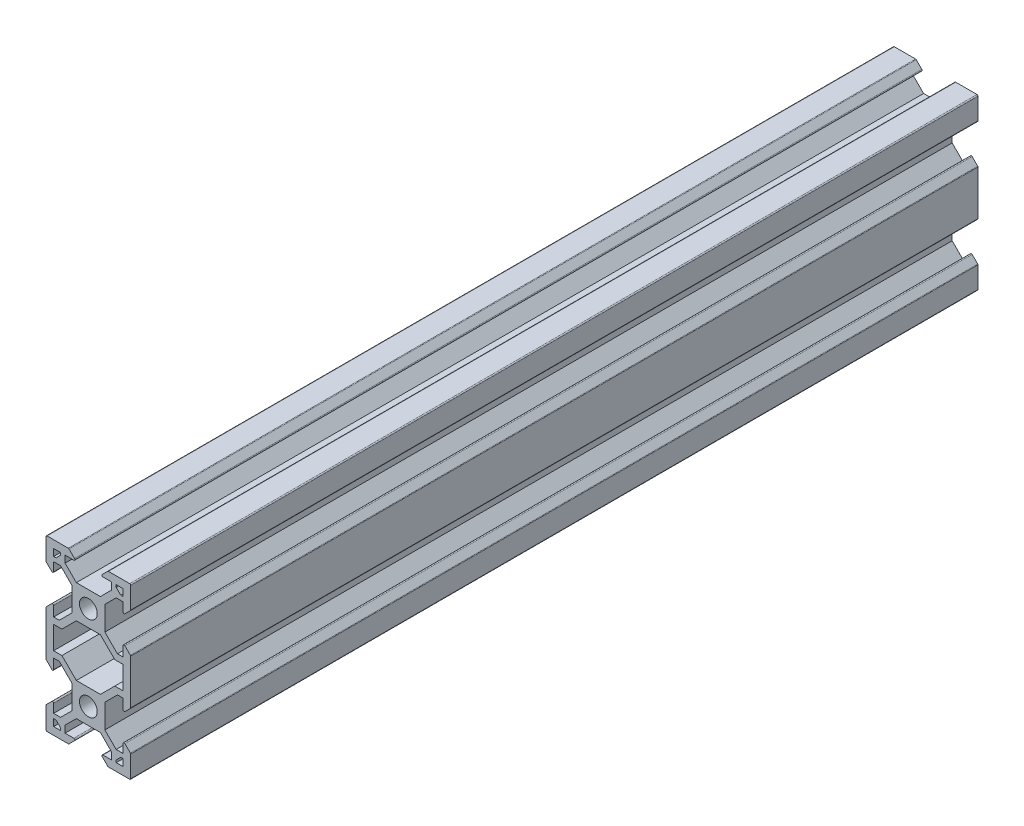
from build123d import *

# Parameters (mm, degrees)
SKETCH1_R            = 2.1
BOSS_EXTRUDE2_DEPTH  = 200
CUT_EXTRUDE1_DEPTH   = 201
FILLET1_R            = 0.25
FILLET1_OF_MIRROR1_R = 0.25


with BuildPart() as part:
    # Sketch1 → Boss-Extrude2 (new body)
    with BuildSketch(Plane.XY):
        Polygon((8.199993721, -10), (9.999993721, -10), (9.999993721, -4.63999575), (8.199993721, -2.84), (8.199993721, -5.800653822), (6.861313026, -5.800653822), (3.900652213, -2.84), (3.900652213, 2.84), (6.559993721, 5.499347787), (8.199993721, 5.499347787), (8.199993721, 2.84), (9.999993721, 4.64000425), (9.999993721, 10), (4.63999575, 10), (2.84, 8.2), (5.499325592, 8.2), (5.499325592, 6.56), (2.84, 3.900668129), (-2.84, 3.900668129), (-5.49933815, 6.56), (-5.49933815, 8.2), (-2.84, 8.2), (-4.64000425, 10), (-10.000006279, 10), (-10.000006279, 4.63999575), (-8.200006279, 2.84), (-8.200006279, 5.499347787), (-6.560006279, 5.499347787), (-3.900652213, 2.84), (-3.900652213, -2.84), (-6.861299044, -5.800653822), (-8.200006279, -5.800653822), (-8.200006279, -2.84), (-10.000006279, -4.64000425), (-10.000006279, -10), (-8.200006279, -10), (-8.200006279, -7.300653822), (-6.239977665, -7.300653822), (-2.84, -3.900668129), (2.84, -3.900668129), (6.239993721, -7.300653822), (8.199993721, -7.300653822), align=None)
        Circle(SKETCH1_R, mode=Mode.SUBTRACT)
    boss_extrude2 = extrude(amount=BOSS_EXTRUDE2_DEPTH)

    # Sketch2 → Cut-Extrude1 (cut, through all)
    with BuildSketch(Plane.XY.offset(200)):
        Polygon((-8.200006279, 6.569347787), (-8.200006279, 8.2), (-6.56933815, 8.2), (-6.56933815, 7.630009211), (-7.62999707, 6.569347787), align=None)
        Polygon((8.199993721, 8.2), (8.199993721, 6.569347787), (7.629987016, 6.569347787), (6.569325592, 7.630006706), (6.569325592, 8.2), align=None)
    cut_extrude1 = extrude(amount=-CUT_EXTRUDE1_DEPTH, mode=Mode.SUBTRACT)

    # Fillet1
    fillet1_edges = [part.edges().sort_by_distance(p)[0] for p in [
        (9.999993721, -4.63999575, 100),
        (-10.000006279, -4.64000425, 100),
        (-8.200006279, -2.84, 100),
        (-8.200006279, 2.84, 100),
        (-10.000006279, 4.63999575, 100),
        (-10.000006279, 10, 100),
        (-4.64000425, 10, 100),
        (-2.84, 8.2, 100),
        (2.84, 8.2, 100),
        (4.63999575, 10, 100),
        (9.999993721, 10, 100),
        (9.999993721, 4.64000425, 100),
        (8.199993721, 2.84, 100),
        (8.199993721, -2.84, 100),
    ]]
    fillet(fillet1_edges, radius=FILLET1_R)

    # Mirror1: Boss-Extrude2 across plane
    add(boss_extrude2.mirror(Plane(origin=(0, -10, 0), x_dir=(0, 0, 1), z_dir=(0, -1, 0))))

    # Fillet1 of Mirror1
    fillet1_of_mirror1_edges = [part.edges().sort_by_distance(p)[0] for p in [
        (9.999993721, -15.36000425, 100),
        (-10.000006279, -15.35999575, 100),
        (-8.200006279, -17.16, 100),
        (-8.200006279, -22.84, 100),
        (-10.000006279, -24.63999575, 100),
        (-10.000006279, -30, 100),
        (-4.64000425, -30, 100),
        (-2.84, -28.2, 100),
        (2.84, -28.2, 100),
        (4.63999575, -30, 100),
        (9.999993721, -30, 100),
        (9.999993721, -24.64000425, 100),
        (8.199993721, -22.84, 100),
        (8.199993721, -17.16, 100),
    ]]
    fillet(fillet1_of_mirror1_edges, radius=FILLET1_OF_MIRROR1_R)

    # Mirror2: Cut-Extrude1 across plane
    add(cut_extrude1.mirror(Plane(origin=(0, -10, 0), x_dir=(0, 0, 1), z_dir=(0, -1, 0))), mode=Mode.SUBTRACT)


solid = part.part
